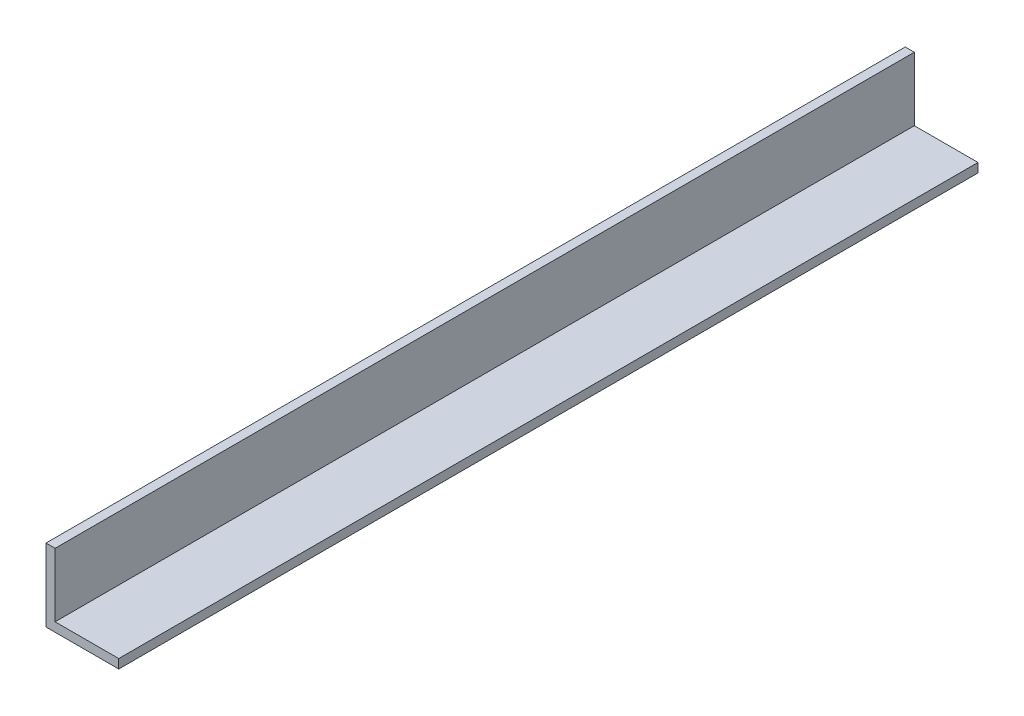
from build123d import *

# Parameters (mm, degrees)
BOSS_EXTRUDE1_DEPTH = 150


with BuildPart() as part:
    # Sketch1 → Boss-Extrude1 (new body, symmetric)
    with BuildSketch(Plane.XY):
        Polygon((0, 25.4), (0, 0), (25.4, 0), (25.4, 3.175), (3.175, 3.175), (3.175, 25.4), align=None)
    extrude(amount=BOSS_EXTRUDE1_DEPTH, both=True)


solid = part.part
